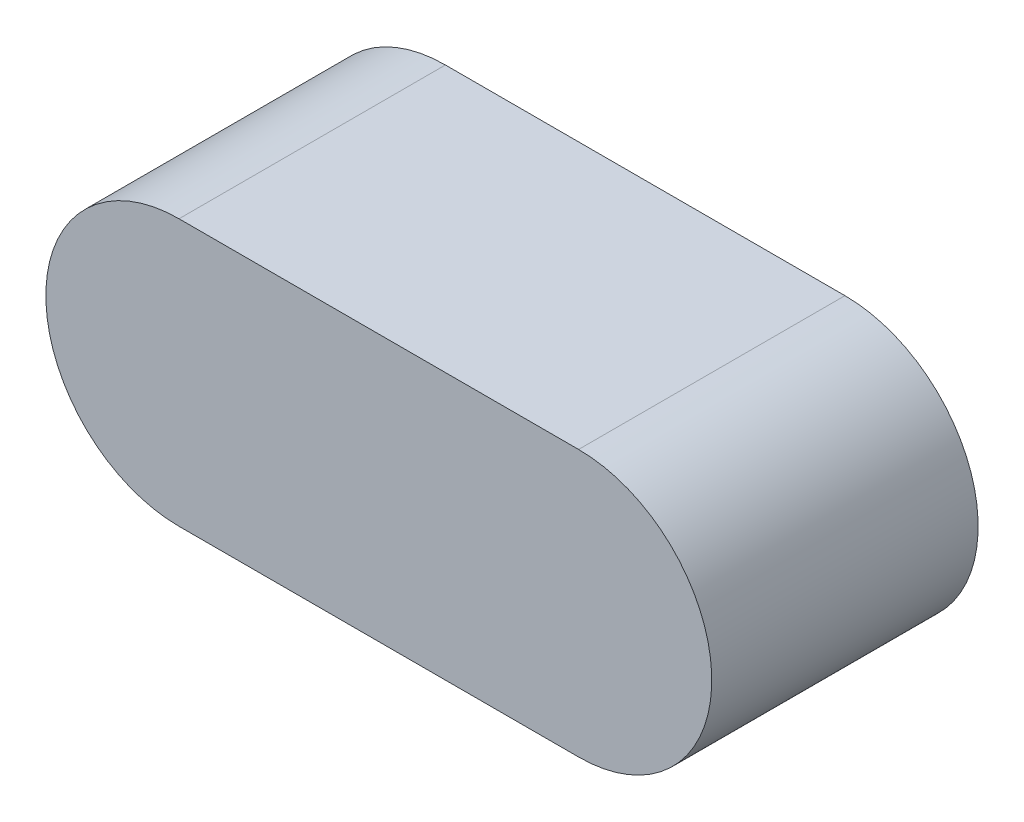
from build123d import *

# Parameters (mm, degrees)
BOSS_EXTRUDE1_DEPTH = 4


with BuildPart() as part:
    # Sketch1 → Boss-Extrude1 (new body)
    with BuildSketch(Plane.XY):
        with BuildLine():
            Line((0, 2), (6, 2))
            ThreePointArc((6, 2), (8, 0), (6, -2))
            Line((6, -2), (0, -2))
            ThreePointArc((0, -2), (-2, 0), (0, 2))
        make_face()
    extrude(amount=BOSS_EXTRUDE1_DEPTH)


solid = part.part
